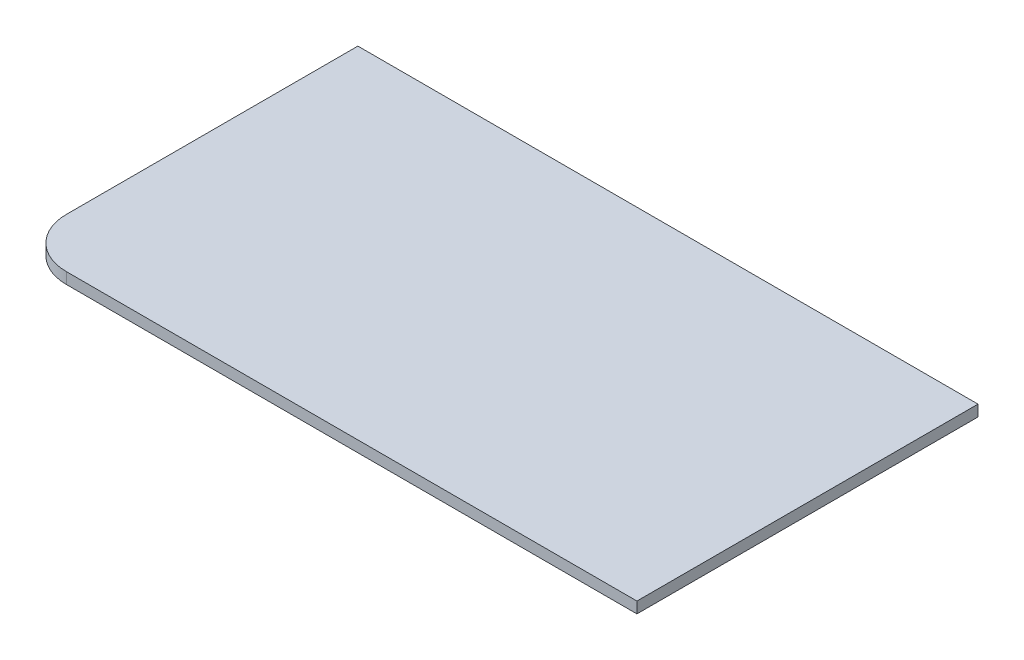
from build123d import *

# Parameters (mm, degrees)
BOSS_EXTRUDE1_DEPTH = 18


with BuildPart() as part:
    # Sketch1 → Boss-Extrude1 (new body)
    with BuildSketch(Plane(origin=(0, 0, 0), x_dir=(1, 0, 0), z_dir=(0, 1, 0))):
        with BuildLine():
            Line((-73.319965759, 75.289506906), (926.680034241, 75.289506906))
            Line((926.680034241, 75.289506906), (926.680034241, -474.710493094))
            Line((926.680034241, -474.710493094), (6.680034241, -474.710493094))
            ThreePointArc((6.680034241, -474.710493094), (-49.888508254, -451.279035589), (-73.319965759, -394.710493094))
            Line((-73.319965759, -394.710493094), (-73.319965759, 75.289506906))
        make_face()
    extrude(amount=BOSS_EXTRUDE1_DEPTH)


solid = part.part
